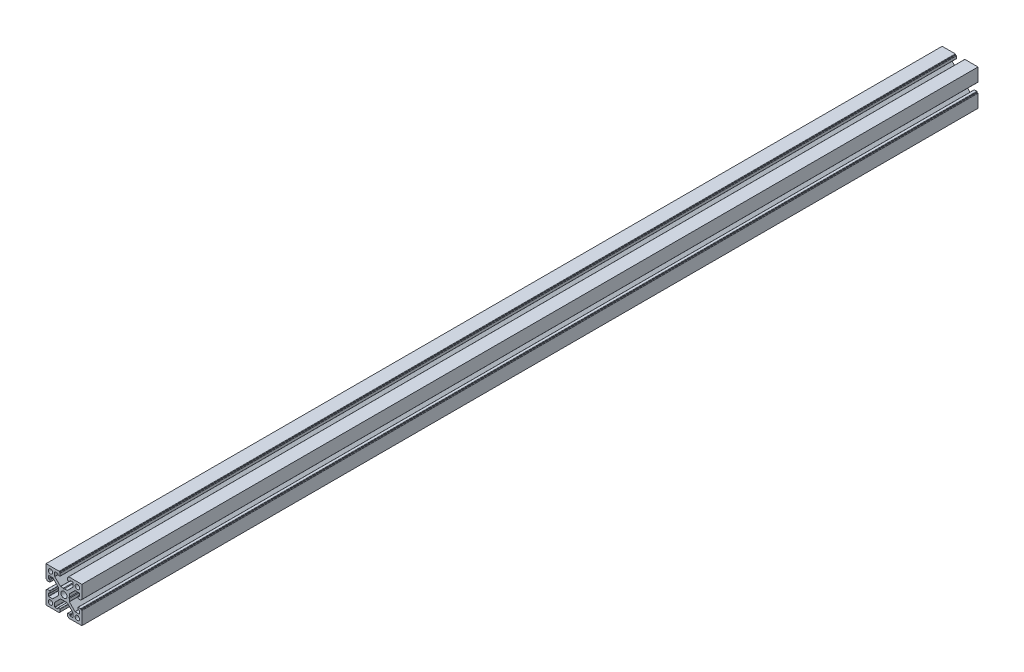
from build123d import *

# Parameters (mm, degrees)
SKETCH_2_R      = 3.4
SKETCH_2_R_2    = 2.45
EXTRUDE_1_DEPTH = 1000


with BuildPart() as part:
    # Эскиз2 → Бобышка-Вытянуть1 (new body)
    with BuildSketch(Plane.XY):
        with BuildLine():
            Line((-20, 10.25), (-20, 20))
            Line((-20, 20), (-10.25, 20))
            Line((-10.25, 20), (-5.4, 20))
            ThreePointArc((-5.4, 20), (-5.187867966, 19.912132034), (-5.1, 19.7))
            Line((-5.1, 19.7), (-5.1, 19))
            Line((-5.1, 19), (-4.4, 19))
            ThreePointArc((-4.4, 19), (-4.187867966, 18.912132034), (-4.1, 18.7))
            Line((-4.1, 18.7), (-4.1, 16))
            ThreePointArc((-4.1, 16), (-4.187867966, 15.787867966), (-4.4, 15.7))
            Line((-4.4, 15.7), (-6.3, 15.7))
            ThreePointArc((-6.3, 15.7), (-6.512132034, 15.787867966), (-6.6, 16))
            Line((-6.6, 16), (-6.6, 16.9))
            ThreePointArc((-6.6, 16.9), (-6.687867966, 17.112132034), (-6.9, 17.2))
            Line((-6.9, 17.2), (-9.95, 17.2))
            ThreePointArc((-9.95, 17.2), (-10.162132034, 17.112132034), (-10.25, 16.9))
            Line((-10.25, 16.9), (-10.25, 12.574264069))
            ThreePointArc((-10.25, 12.574264069), (-10.22716386, 12.459459039), (-10.162132034, 12.362132034))
            Line((-10.162132034, 12.362132034), (-3.887867966, 6.087867966))
            ThreePointArc((-3.887867966, 6.087867966), (-3.790540961, 6.02283614), (-3.675735931, 6))
            Line((-3.675735931, 6), (-0.6, 6))
            Line((-0.6, 6), (0, 5.4))
            Line((0, 5.4), (0.6, 6))
            Line((0.6, 6), (3.675735931, 6))
            ThreePointArc((3.675735931, 6), (3.790540961, 6.02283614), (3.887867966, 6.087867966))
            Line((3.887867966, 6.087867966), (10.162132034, 12.362132034))
            ThreePointArc((10.162132034, 12.362132034), (10.22716386, 12.459459039), (10.25, 12.574264069))
            Line((10.25, 12.574264069), (10.25, 16.9))
            ThreePointArc((10.25, 16.9), (10.162132034, 17.112132034), (9.95, 17.2))
            Line((9.95, 17.2), (6.9, 17.2))
            ThreePointArc((6.9, 17.2), (6.687867966, 17.112132034), (6.6, 16.9))
            Line((6.6, 16.9), (6.6, 16))
            ThreePointArc((6.6, 16), (6.512132034, 15.787867966), (6.3, 15.7))
            Line((6.3, 15.7), (4.4, 15.7))
            ThreePointArc((4.4, 15.7), (4.187867966, 15.787867966), (4.1, 16))
            Line((4.1, 16), (4.1, 18.7))
            ThreePointArc((4.1, 18.7), (4.187867966, 18.912132034), (4.4, 19))
            Line((4.4, 19), (5.1, 19))
            Line((5.1, 19), (5.1, 19.7))
            ThreePointArc((5.1, 19.7), (5.187867966, 19.912132034), (5.4, 20))
            Line((5.4, 20), (10.25, 20))
            Line((10.25, 20), (20, 20))
            Line((20, 20), (20, 10.25))
            Line((20, 10.25), (20, 5.4))
            ThreePointArc((20, 5.4), (19.912132034, 5.187867966), (19.7, 5.1))
            Line((19.7, 5.1), (19, 5.1))
            Line((19, 5.1), (19, 4.4))
            ThreePointArc((19, 4.4), (18.912132034, 4.187867966), (18.7, 4.1))
            Line((18.7, 4.1), (16, 4.1))
            ThreePointArc((16, 4.1), (15.787867966, 4.187867966), (15.7, 4.4))
            Line((15.7, 4.4), (15.7, 6.3))
            ThreePointArc((15.7, 6.3), (15.787867966, 6.512132034), (16, 6.6))
            Line((16, 6.6), (16.9, 6.6))
            ThreePointArc((16.9, 6.6), (17.112132034, 6.687867966), (17.2, 6.9))
            Line((17.2, 6.9), (17.2, 9.95))
            ThreePointArc((17.2, 9.95), (17.112132034, 10.162132034), (16.9, 10.25))
            Line((16.9, 10.25), (12.574264069, 10.25))
            ThreePointArc((12.574264069, 10.25), (12.459459039, 10.22716386), (12.362132034, 10.162132034))
            Line((12.362132034, 10.162132034), (6.087867966, 3.887867966))
            ThreePointArc((6.087867966, 3.887867966), (6.02283614, 3.790540961), (6, 3.675735931))
            Line((6, 3.675735931), (6, 0.6))
            Line((6, 0.6), (5.4, 0))
            Line((5.4, 0), (6, -0.6))
            Line((6, -0.6), (6, -3.675735931))
            ThreePointArc((6, -3.675735931), (6.02283614, -3.790540961), (6.087867966, -3.887867966))
            Line((6.087867966, -3.887867966), (12.362132034, -10.162132034))
            ThreePointArc((12.362132034, -10.162132034), (12.459459039, -10.22716386), (12.574264069, -10.25))
            Line((12.574264069, -10.25), (16.9, -10.25))
            ThreePointArc((16.9, -10.25), (17.112132034, -10.162132034), (17.2, -9.95))
            Line((17.2, -9.95), (17.2, -6.9))
            ThreePointArc((17.2, -6.9), (17.112132034, -6.687867966), (16.9, -6.6))
            Line((16.9, -6.6), (16, -6.6))
            ThreePointArc((16, -6.6), (15.787867966, -6.512132034), (15.7, -6.3))
            Line((15.7, -6.3), (15.7, -4.4))
            ThreePointArc((15.7, -4.4), (15.787867966, -4.187867966), (16, -4.1))
            Line((16, -4.1), (18.7, -4.1))
            ThreePointArc((18.7, -4.1), (18.912132034, -4.187867966), (19, -4.4))
            Line((19, -4.4), (19, -5.1))
            Line((19, -5.1), (19.7, -5.1))
            ThreePointArc((19.7, -5.1), (19.912132034, -5.187867966), (20, -5.4))
            Line((20, -5.4), (20, -10.25))
            Line((20, -10.25), (20, -20))
            Line((20, -20), (10.25, -20))
            Line((10.25, -20), (5.4, -20))
            ThreePointArc((5.4, -20), (5.187867966, -19.912132034), (5.1, -19.7))
            Line((5.1, -19.7), (5.1, -19))
            Line((5.1, -19), (4.4, -19))
            ThreePointArc((4.4, -19), (4.187867966, -18.912132034), (4.1, -18.7))
            Line((4.1, -18.7), (4.1, -16))
            ThreePointArc((4.1, -16), (4.187867966, -15.787867966), (4.4, -15.7))
            Line((4.4, -15.7), (6.3, -15.7))
            ThreePointArc((6.3, -15.7), (6.512132034, -15.787867966), (6.6, -16))
            Line((6.6, -16), (6.6, -16.9))
            ThreePointArc((6.6, -16.9), (6.687867966, -17.112132034), (6.9, -17.2))
            Line((6.9, -17.2), (9.95, -17.2))
            ThreePointArc((9.95, -17.2), (10.162132034, -17.112132034), (10.25, -16.9))
            Line((10.25, -16.9), (10.25, -12.574264069))
            ThreePointArc((10.25, -12.574264069), (10.22716386, -12.459459039), (10.162132034, -12.362132034))
            Line((10.162132034, -12.362132034), (3.887867966, -6.087867966))
            ThreePointArc((3.887867966, -6.087867966), (3.790540961, -6.02283614), (3.675735931, -6))
            Line((3.675735931, -6), (0.6, -6))
            Line((0.6, -6), (0, -5.4))
            Line((0, -5.4), (-0.6, -6))
            Line((-0.6, -6), (-3.675735931, -6))
            ThreePointArc((-3.675735931, -6), (-3.790540961, -6.02283614), (-3.887867966, -6.087867966))
            Line((-3.887867966, -6.087867966), (-10.162132034, -12.362132034))
            ThreePointArc((-10.162132034, -12.362132034), (-10.22716386, -12.459459039), (-10.25, -12.574264069))
            Line((-10.25, -12.574264069), (-10.25, -16.9))
            ThreePointArc((-10.25, -16.9), (-10.162132034, -17.112132034), (-9.95, -17.2))
            Line((-9.95, -17.2), (-6.9, -17.2))
            ThreePointArc((-6.9, -17.2), (-6.687867966, -17.112132034), (-6.6, -16.9))
            Line((-6.6, -16.9), (-6.6, -16))
            ThreePointArc((-6.6, -16), (-6.512132034, -15.787867966), (-6.3, -15.7))
            Line((-6.3, -15.7), (-4.4, -15.7))
            ThreePointArc((-4.4, -15.7), (-4.187867966, -15.787867966), (-4.1, -16))
            Line((-4.1, -16), (-4.1, -18.7))
            ThreePointArc((-4.1, -18.7), (-4.187867966, -18.912132034), (-4.4, -19))
            Line((-4.4, -19), (-5.1, -19))
            Line((-5.1, -19), (-5.1, -19.7))
            ThreePointArc((-5.1, -19.7), (-5.187867966, -19.912132034), (-5.4, -20))
            Line((-5.4, -20), (-10.25, -20))
            Line((-10.25, -20), (-20, -20))
            Line((-20, -20), (-20, -10.25))
            Line((-20, -10.25), (-20, -5.4))
            ThreePointArc((-20, -5.4), (-19.912132034, -5.187867966), (-19.7, -5.1))
            Line((-19.7, -5.1), (-19, -5.1))
            Line((-19, -5.1), (-19, -4.4))
            ThreePointArc((-19, -4.4), (-18.912132034, -4.187867966), (-18.7, -4.1))
            Line((-18.7, -4.1), (-16, -4.1))
            ThreePointArc((-16, -4.1), (-15.787867966, -4.187867966), (-15.7, -4.4))
            Line((-15.7, -4.4), (-15.7, -6.3))
            ThreePointArc((-15.7, -6.3), (-15.787867966, -6.512132034), (-16, -6.6))
            Line((-16, -6.6), (-16.9, -6.6))
            ThreePointArc((-16.9, -6.6), (-17.112132034, -6.687867966), (-17.2, -6.9))
            Line((-17.2, -6.9), (-17.2, -9.95))
            ThreePointArc((-17.2, -9.95), (-17.112132034, -10.162132034), (-16.9, -10.25))
            Line((-16.9, -10.25), (-12.574264069, -10.25))
            ThreePointArc((-12.574264069, -10.25), (-12.459459039, -10.22716386), (-12.362132034, -10.162132034))
            Line((-12.362132034, -10.162132034), (-6.087867966, -3.887867966))
            ThreePointArc((-6.087867966, -3.887867966), (-6.02283614, -3.790540961), (-6, -3.675735931))
            Line((-6, -3.675735931), (-6, -0.6))
            Line((-6, -0.6), (-5.4, 0))
            Line((-5.4, 0), (-6, 0.6))
            Line((-6, 0.6), (-6, 3.675735931))
            ThreePointArc((-6, 3.675735931), (-6.02283614, 3.790540961), (-6.087867966, 3.887867966))
            Line((-6.087867966, 3.887867966), (-12.362132034, 10.162132034))
            ThreePointArc((-12.362132034, 10.162132034), (-12.459459039, 10.22716386), (-12.574264069, 10.25))
            Line((-12.574264069, 10.25), (-16.9, 10.25))
            ThreePointArc((-16.9, 10.25), (-17.112132034, 10.162132034), (-17.2, 9.95))
            Line((-17.2, 9.95), (-17.2, 6.9))
            ThreePointArc((-17.2, 6.9), (-17.112132034, 6.687867966), (-16.9, 6.6))
            Line((-16.9, 6.6), (-16, 6.6))
            ThreePointArc((-16, 6.6), (-15.787867966, 6.512132034), (-15.7, 6.3))
            Line((-15.7, 6.3), (-15.7, 4.4))
            ThreePointArc((-15.7, 4.4), (-15.787867966, 4.187867966), (-16, 4.1))
            Line((-16, 4.1), (-18.7, 4.1))
            ThreePointArc((-18.7, 4.1), (-18.912132034, 4.187867966), (-19, 4.4))
            Line((-19, 4.4), (-19, 5.1))
            Line((-19, 5.1), (-19.7, 5.1))
            ThreePointArc((-19.7, 5.1), (-19.912132034, 5.187867966), (-20, 5.4))
            Line((-20, 5.4), (-20, 10.25))
        make_face()
        Circle(SKETCH_2_R, mode=Mode.SUBTRACT)
        with Locations((-15, 15)):
            Circle(SKETCH_2_R_2, mode=Mode.SUBTRACT)
        with Locations((15, 15)):
            Circle(SKETCH_2_R_2, mode=Mode.SUBTRACT)
        with Locations((15, -15)):
            Circle(SKETCH_2_R_2, mode=Mode.SUBTRACT)
        with Locations((-15, -15)):
            Circle(SKETCH_2_R_2, mode=Mode.SUBTRACT)
    extrude(amount=EXTRUDE_1_DEPTH)


solid = part.part
